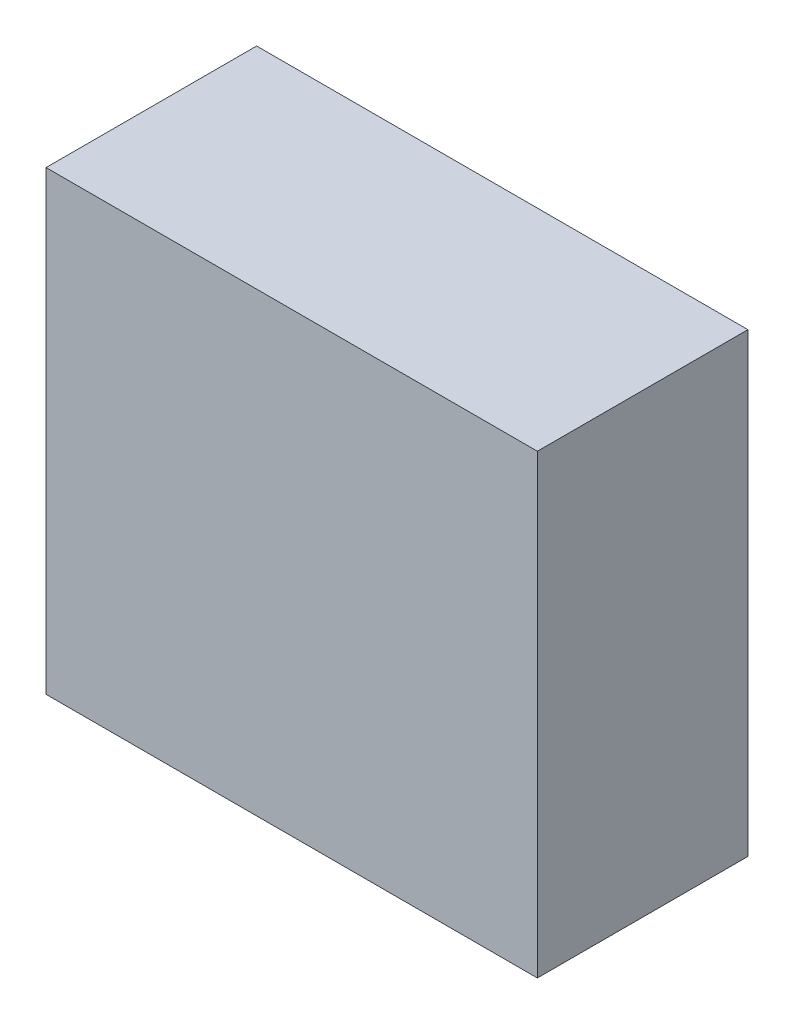
from build123d import *

# Parameters (mm, degrees)
SKETCH1_W           = 177.8
SKETCH1_H           = 76.2
BOSS_EXTRUDE1_DEPTH = 82.55


with BuildPart() as part:
    # Sketch1 → Boss-Extrude1 (new body, symmetric)
    with BuildSketch(Plane(origin=(0, 0, 0), x_dir=(1, 0, 0), z_dir=(0, 1, 0))):
        Rectangle(SKETCH1_W, SKETCH1_H)
    extrude(amount=BOSS_EXTRUDE1_DEPTH, both=True)


solid = part.part
